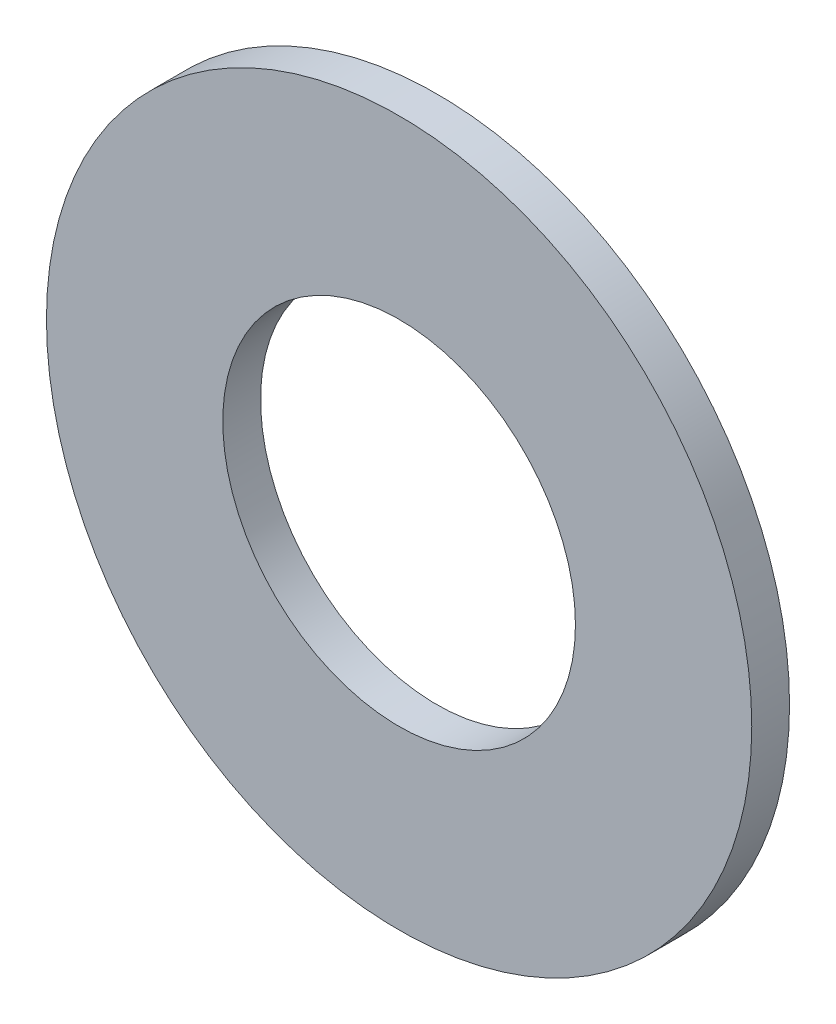
from build123d import *

# Parameters (mm, degrees)
SKETCH1_R           = 14
SKETCH1_R_2         = 7
BOSS_EXTRUDE1_DEPTH = 1.5


with BuildPart() as part:
    # Sketch1 → Boss-Extrude1 (new body)
    with BuildSketch(Plane.XY):
        Circle(SKETCH1_R)
        Circle(SKETCH1_R_2, mode=Mode.SUBTRACT)
    extrude(amount=BOSS_EXTRUDE1_DEPTH)


solid = part.part
